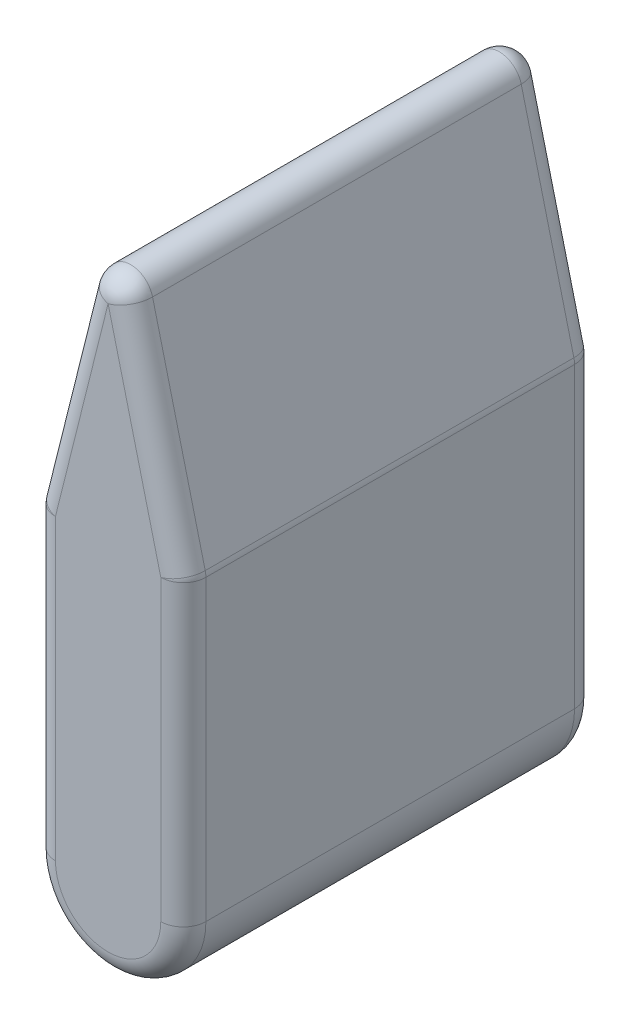
from build123d import *

# Parameters (mm, degrees)
BOSS_EXTRUDE1_DEPTH = 27.5
FILLET1_R           = 3


with BuildPart() as part:
    # Sketch1 → Boss-Extrude1 (new body, symmetric)
    with BuildSketch(Plane.XY):
        with BuildLine():
            Line((-10, 0), (-10, 40))
            Line((-10, 40), (0, 80))
            Line((0, 80), (10, 40))
            Line((10, 40), (10, 0))
            ThreePointArc((10, 0), (0, -10), (-10, 0))
        make_face()
    extrude(amount=BOSS_EXTRUDE1_DEPTH, both=True)

    # Fillet1
    fillet1_edges = [part.edges().sort_by_distance(p)[0] for p in [
        (5, 60, 27.5),
        (-5, 60, 27.5),
        (-10, 20, 27.5),
        (0, -10, 27.5),
        (-10, 20, -27.5),
        (-5, 60, -27.5),
        (5, 60, -27.5),
        (10, 20, -27.5),
        (0, -10, -27.5),
        (10, 20, 27.5),
        (-10, 40, 0),
        (0, 80, 0),
        (10, 40, 0),
    ]]
    fillet(fillet1_edges, radius=FILLET1_R)


solid = part.part
